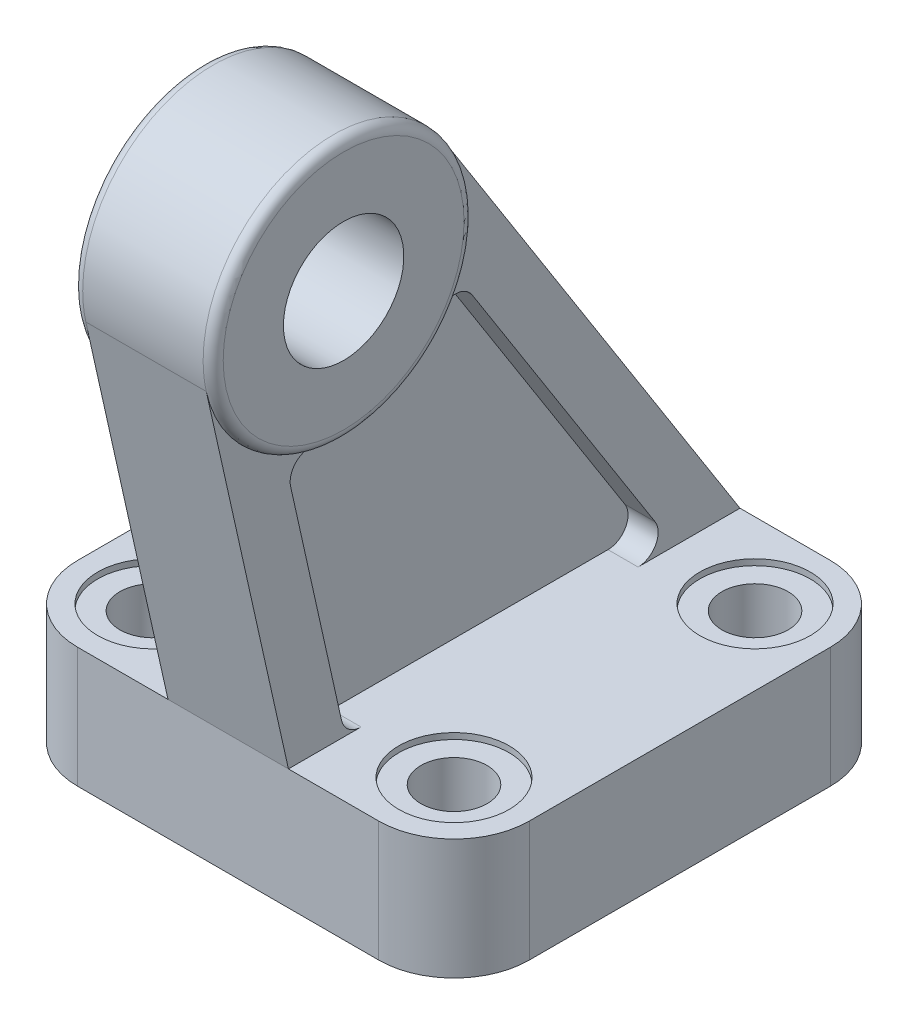
from build123d import *

# Parameters (mm, degrees)
SKETCH1_R                = 3.3
BOSS_EXTRUDE1_DEPTH      = 12
BOSS_EXTRUDE2_DEPTH      = 6
BOSS_EXTRUDE2_DEPTH_BACK = 6
CUT_EXTRUDE1_DEPTH       = 3
CUT_EXTRUDE2_DEPTH       = 3
CUT_EXTRUDE3_DEPTH       = 6
SKETCH7_R                = 5.5
CUT_EXTRUDE4_DEPTH       = 0.6
SKETCH8_R                = 5.5
CUT_EXTRUDE5_DEPTH       = 0.6
SKETCH9_R                = 5.5
CUT_EXTRUDE6_DEPTH       = 0.6
SKETCH10_R               = 5.5
CUT_EXTRUDE7_DEPTH       = 0.6


with BuildPart() as part:
    # Sketch1 → Boss-Extrude1 (new body)
    with BuildSketch(Plane(origin=(0, 0, 0), x_dir=(1, 0, 0), z_dir=(0, 1, 0))):
        with BuildLine():
            Line((-15, -22.5), (15, -22.5))
            ThreePointArc((15, -22.5), (20.303300859, -20.303300859), (22.5, -15))
            Line((22.5, -15), (22.5, 15))
            ThreePointArc((22.5, 15), (20.303300859, 20.303300859), (15, 22.5))
            Line((15, 22.5), (-15, 22.5))
            ThreePointArc((-15, 22.5), (-20.303300859, 20.303300859), (-22.5, 15))
            Line((-22.5, 15), (-22.5, -15))
            ThreePointArc((-22.5, -15), (-20.303300859, -20.303300859), (-15, -22.5))
        make_face()
        with Locations((15, 15)):
            Circle(SKETCH1_R, mode=Mode.SUBTRACT)
        with Locations((15, -15)):
            Circle(SKETCH1_R, mode=Mode.SUBTRACT)
        with Locations((-15, 15)):
            Circle(SKETCH1_R, mode=Mode.SUBTRACT)
        with Locations((-15, -15)):
            Circle(SKETCH1_R, mode=Mode.SUBTRACT)
    extrude(amount=BOSS_EXTRUDE1_DEPTH)

    # Sketch2 → Boss-Extrude2 (add, two sides)
    with BuildSketch(Plane(origin=(0, 0, 0), x_dir=(0, 0, -1), z_dir=(1, 0, 0))) as boss_extrude2_sk:
        with BuildLine():
            Line((-30.687542875, 48.666935264), (-22.5, 12))
            Line((-22.5, 12), (22.5, 12))
            Line((22.5, 12), (-7.027549789, 58.471752748))
            ThreePointArc((-7.027549789, 58.471752748), (-13.023153892, 39.49037874), (-30.687542875, 48.666935264))
        make_face()
    extrude(amount=BOSS_EXTRUDE2_DEPTH)
    extrude(boss_extrude2_sk.sketch, amount=-BOSS_EXTRUDE2_DEPTH_BACK)

    # Sketch3 → Cut-Extrude1 (cut)
    with BuildSketch(Plane(origin=(6, 0, 0), x_dir=(0, 0, -1), z_dir=(1, 0, 0))):
        with BuildLine():
            Line((-22.278487974, 36.245671412), (-17.213816554, 13.564143887))
            ThreePointArc((-17.213816554, 13.564143887), (-16.512544263, 12.439277054), (-15.261886881, 12))
            Line((-15.261886881, 12), (12.343334592, 12))
            ThreePointArc((12.343334592, 12), (14.096211469, 13.036972143), (14.031403855, 15.072577346))
            Line((14.031403855, 15.072577346), (-4.185678595, 43.743420591))
            ThreePointArc((-4.185678595, 43.743420591), (-5.810453328, 44.669841445), (-7.490581477, 43.848064146))
            ThreePointArc((-7.490581477, 43.848064146), (-13.023153892, 39.49037874), (-20.016350528, 38.657323856))
            ThreePointArc((-20.016350528, 38.657323856), (-21.785266488, 38.049800314), (-22.278487974, 36.245671412))
        make_face()
    extrude(amount=-CUT_EXTRUDE1_DEPTH, mode=Mode.SUBTRACT)

    # Sketch4 → Cut-Extrude2 (cut)
    with BuildSketch(Plane(origin=(-6, 0, 0), x_dir=(0, 0, -1), z_dir=(1, 0, 0))):
        with BuildLine():
            Line((-22.278487974, 36.245671412), (-17.213816554, 13.564143887))
            ThreePointArc((-17.213816554, 13.564143887), (-16.512544263, 12.439277054), (-15.261886881, 12))
            Line((-15.261886881, 12), (12.343334592, 12))
            ThreePointArc((12.343334592, 12), (14.096211469, 13.036972143), (14.031403855, 15.072577346))
            Line((14.031403855, 15.072577346), (-4.185678595, 43.743420591))
            ThreePointArc((-4.185678595, 43.743420591), (-5.810453328, 44.669841445), (-7.490581477, 43.848064146))
            ThreePointArc((-7.490581477, 43.848064146), (-13.023153892, 39.49037874), (-20.016350528, 38.657323856))
            ThreePointArc((-20.016350528, 38.657323856), (-21.785266488, 38.049800314), (-22.278487974, 36.245671412))
        make_face()
    extrude(amount=CUT_EXTRUDE2_DEPTH, mode=Mode.SUBTRACT)

    # Sketch5 → Revolve1 (revolve)
    with BuildSketch(Plane.XY.offset(18)):
        with BuildLine():
            Line((-7, 63.5), (-7, 57.5))
            Line((-7, 57.5), (7, 57.5))
            Line((7, 57.5), (7, 63.5))
            ThreePointArc((7, 63.5), (6.707106781, 64.207106781), (6, 64.5))
            Line((6, 64.5), (-6, 64.5))
            ThreePointArc((-6, 64.5), (-6.707106781, 64.207106781), (-7, 63.5))
        make_face()
    revolve(axis=Axis((7, 51.5, 18), (-1, 0, 0)))

    # Sketch6 → Cut-Extrude3 (cut)
    with BuildSketch(Plane(origin=(0, 0, 0), x_dir=(1, 0, 0), z_dir=(0, 1, 0))):
        with BuildLine():
            Line((-17, 6.5), (-17, -6.5))
            ThreePointArc((-17, -6.5), (-16.414213562, -7.914213562), (-15, -8.5))
            ThreePointArc((-15, -8.5), (-10.403805922, -10.403805922), (-8.5, -15))
            ThreePointArc((-8.5, -15), (-7.914213562, -16.414213562), (-6.5, -17))
            Line((-6.5, -17), (6.5, -17))
            ThreePointArc((6.5, -17), (7.914213562, -16.414213562), (8.5, -15))
            ThreePointArc((8.5, -15), (10.403805922, -10.403805922), (15, -8.5))
            ThreePointArc((15, -8.5), (16.414213562, -7.914213562), (17, -6.5))
            Line((17, -6.5), (17, 6.5))
            ThreePointArc((17, 6.5), (16.414213562, 7.914213562), (15, 8.5))
            ThreePointArc((15, 8.5), (10.403805922, 10.403805922), (8.5, 15))
            ThreePointArc((8.5, 15), (7.914213562, 16.414213562), (6.5, 17))
            Line((6.5, 17), (-6.5, 17))
            ThreePointArc((-6.5, 17), (-7.914213562, 16.414213562), (-8.5, 15))
            ThreePointArc((-8.5, 15), (-10.403805922, 10.403805922), (-15, 8.5))
            ThreePointArc((-15, 8.5), (-16.414213562, 7.914213562), (-17, 6.5))
        make_face()
    extrude(amount=CUT_EXTRUDE3_DEPTH, mode=Mode.SUBTRACT)

    # Sketch7 → Cut-Extrude4 (cut)
    with BuildSketch(Plane(origin=(0, 12, 0), x_dir=(1, 0, 0), z_dir=(0, 1, 0))):
        with Locations((15, 15)):
            Circle(SKETCH7_R)
    extrude(amount=-CUT_EXTRUDE4_DEPTH, mode=Mode.SUBTRACT)

    # Sketch8 → Cut-Extrude5 (cut)
    with BuildSketch(Plane(origin=(0, 12, 0), x_dir=(1, 0, 0), z_dir=(0, 1, 0))):
        with Locations((-15, 15)):
            Circle(SKETCH8_R)
    extrude(amount=-CUT_EXTRUDE5_DEPTH, mode=Mode.SUBTRACT)

    # Sketch9 → Cut-Extrude6 (cut)
    with BuildSketch(Plane(origin=(0, 12, 0), x_dir=(1, 0, 0), z_dir=(0, 1, 0))):
        with Locations((15, -15)):
            Circle(SKETCH9_R)
    extrude(amount=-CUT_EXTRUDE6_DEPTH, mode=Mode.SUBTRACT)

    # Sketch10 → Cut-Extrude7 (cut)
    with BuildSketch(Plane(origin=(0, 12, 0), x_dir=(1, 0, 0), z_dir=(0, 1, 0))):
        with Locations((-15, -15)):
            Circle(SKETCH10_R)
    extrude(amount=-CUT_EXTRUDE7_DEPTH, mode=Mode.SUBTRACT)


solid = part.part
